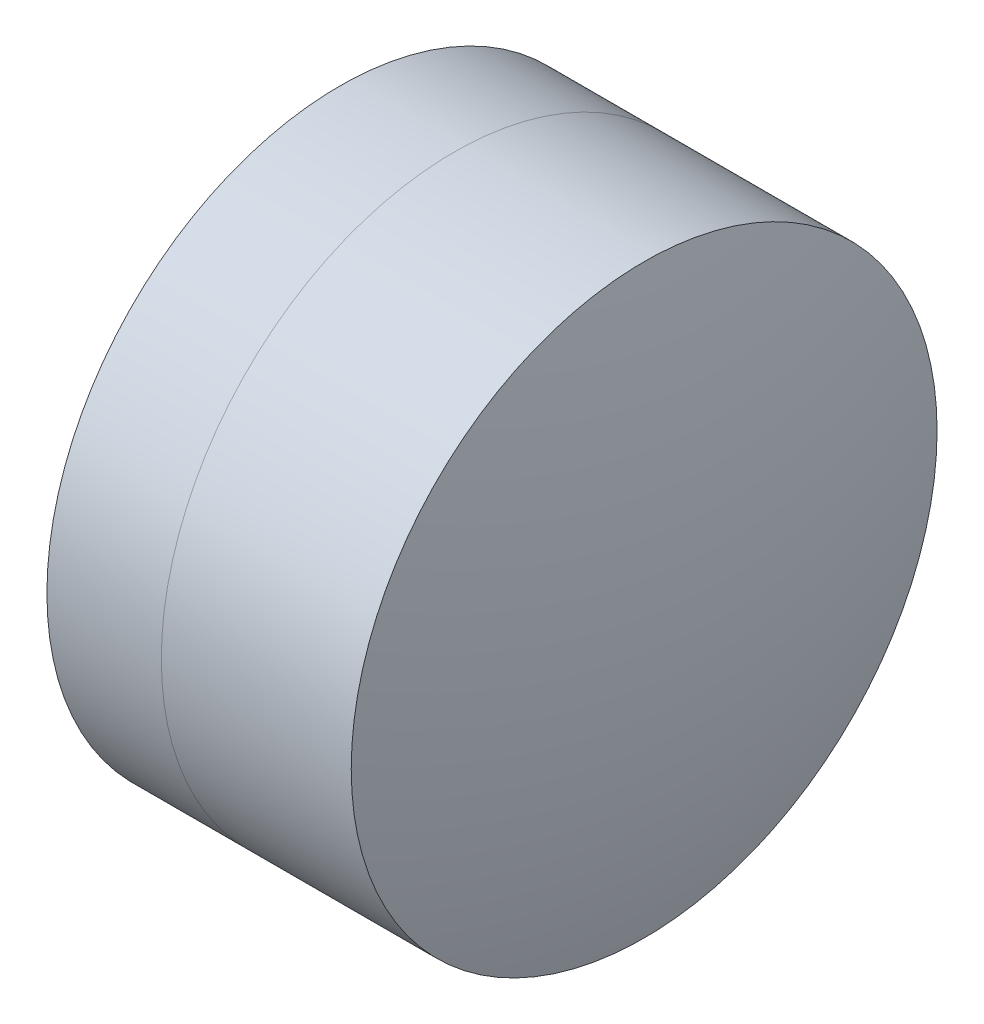
from build123d import *


with BuildPart() as part:
    # 草图1 one side → 旋转1 (revolve)
    with BuildSketch(Plane(origin=(0, 0, 0), x_dir=(1, 0, 0), z_dir=(0, 1, 0)), mode=Mode.PRIVATE) as revolve_1_sk:
        with BuildLine():
            ThreePointArc((1.137008305, 3.175), (0.845584068, 1.599373626), (0.747959484, 0))
            Line((0.747959484, 0), (3.547959484, 0))
            ThreePointArc((3.547959484, 0), (3.245897361, 1.692018333), (2.377028588, 3.175))
            Line((2.377028588, 3.175), (1.137008305, 3.175))
        make_face()
    revolve(revolve_1_sk.sketch.rotate(Axis((-0.816062176, 0, 0), (1, 0, 0)), 180), axis=Axis((-0.816062176, 0, 0), (1, 0, 0)))  # turned: the seam where the file's is


with BuildPart() as body_2:
    # 草图2 one side → 旋转2 (revolve)
    with BuildSketch(Plane(origin=(0, 0, 0), x_dir=(1, 0, 0), z_dir=(0, 1, 0)), mode=Mode.PRIVATE) as revolve_2_sk:
        with BuildLine():
            Line((4.435281209, 3.175), (2.377028588, 3.175))
            ThreePointArc((2.377028588, 3.175), (3.245897361, 1.692018333), (3.547959484, 0))
            Line((3.547959484, 0), (4.847959484, 0))
            ThreePointArc((4.847959484, 0), (4.744357818, 1.60085355), (4.435281209, 3.175))
        make_face()
    revolve(revolve_2_sk.sketch.rotate(Axis((-0.551919993, 0, 0), (1, 0, 0)), 180), axis=Axis((-0.551919993, 0, 0), (1, 0, 0)))  # turned: the seam where the file's is


solid = Compound([part.part, body_2.part])
